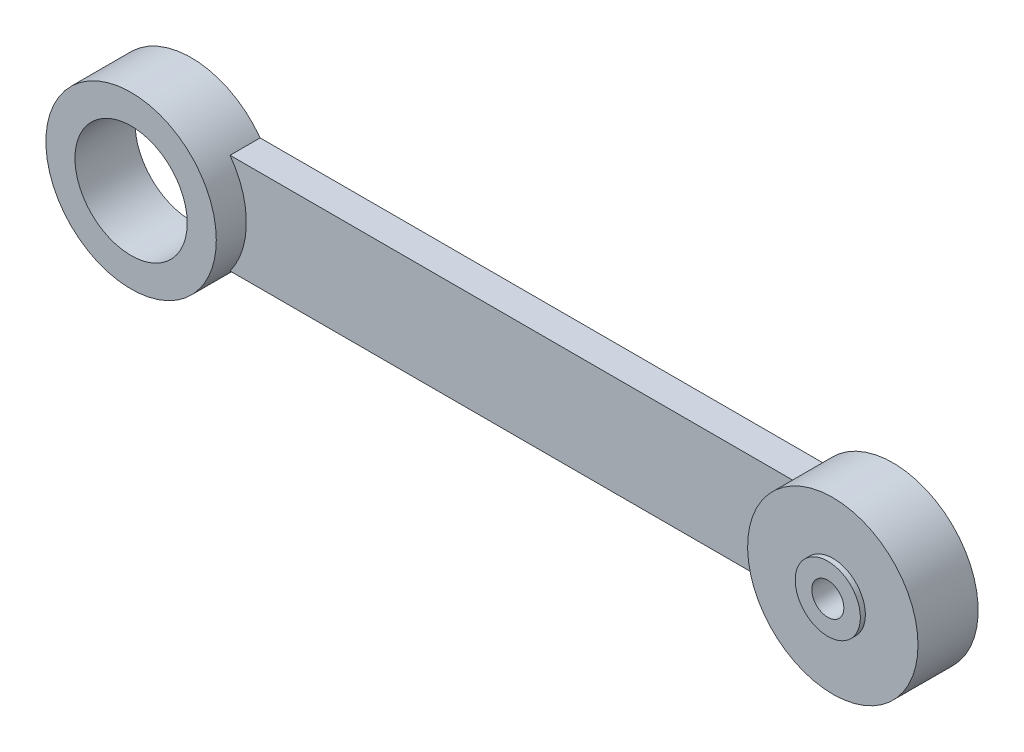
from build123d import *

# Parameters (mm, degrees)
SKETCH1_R           = 5.6
BOSS_EXTRUDE1_DEPTH = 3
SKETCH2_R           = 8.5
SKETCH2_R_2         = 5.6
BOSS_EXTRUDE2_DEPTH = 6
SKETCH3_R           = 8.5
BOSS_EXTRUDE3_DEPTH = 6
SKETCH4_R           = 1.6
CUT_EXTRUDE1_DEPTH  = 80.186488747
SKETCH5_R           = 3.3
CUT_EXTRUDE2_DEPTH  = 1.5
BOSS_EXTRUDE4_START = 6
SKETCH6_R           = 3.25
SKETCH6_R_2         = 1.6
BOSS_EXTRUDE4_DEPTH = 0.5


with BuildPart() as part:
    # Sketch1 → Boss-Extrude1 (new body)
    with BuildSketch(Plane.XY):
        with BuildLine():
            Line((6.873863542, 5), (63.126136458, 5))
            ThreePointArc((63.126136458, 5), (78.5, 0), (63.126136458, -5))
            Line((63.126136458, -5), (6.873863542, -5))
            ThreePointArc((6.873863542, -5), (-8.5, 0), (6.873863542, 5))
        make_face()
        Circle(SKETCH1_R, mode=Mode.SUBTRACT)
    extrude(amount=BOSS_EXTRUDE1_DEPTH)

    # Sketch2 → Boss-Extrude2 (add)
    with BuildSketch(Plane.XY):
        with Locations(Location((0, 0, 0), (0, 0, 323.968120928))):
            Circle(SKETCH2_R)
        Circle(SKETCH2_R_2, mode=Mode.SUBTRACT)
    extrude(amount=BOSS_EXTRUDE2_DEPTH)

    # Sketch3 → Boss-Extrude3 (add)
    with BuildSketch(Plane.XY):
        with Locations(Location((70, 0, 0), (0, 0, 216.031879072))):
            Circle(SKETCH3_R)
    extrude(amount=BOSS_EXTRUDE3_DEPTH)

    # Sketch4 → Cut-Extrude1 (cut, through all)
    with BuildSketch(Plane.XY):
        with Locations((70, 0)):
            Circle(SKETCH4_R)
    extrude(amount=CUT_EXTRUDE1_DEPTH, mode=Mode.SUBTRACT)

    # Sketch5 → Cut-Extrude2 (cut)
    with BuildSketch(Plane.XY):
        with Locations((70, 0)):
            Circle(SKETCH5_R)
    extrude(amount=CUT_EXTRUDE2_DEPTH, mode=Mode.SUBTRACT)

    # Sketch6 → Boss-Extrude4 (add)
    with BuildSketch(Plane.XY.offset(BOSS_EXTRUDE4_START)):
        with Locations((70, 0)):
            Circle(SKETCH6_R)
        with Locations((70, 0)):
            Circle(SKETCH6_R_2, mode=Mode.SUBTRACT)
    extrude(amount=BOSS_EXTRUDE4_DEPTH)


solid = part.part
